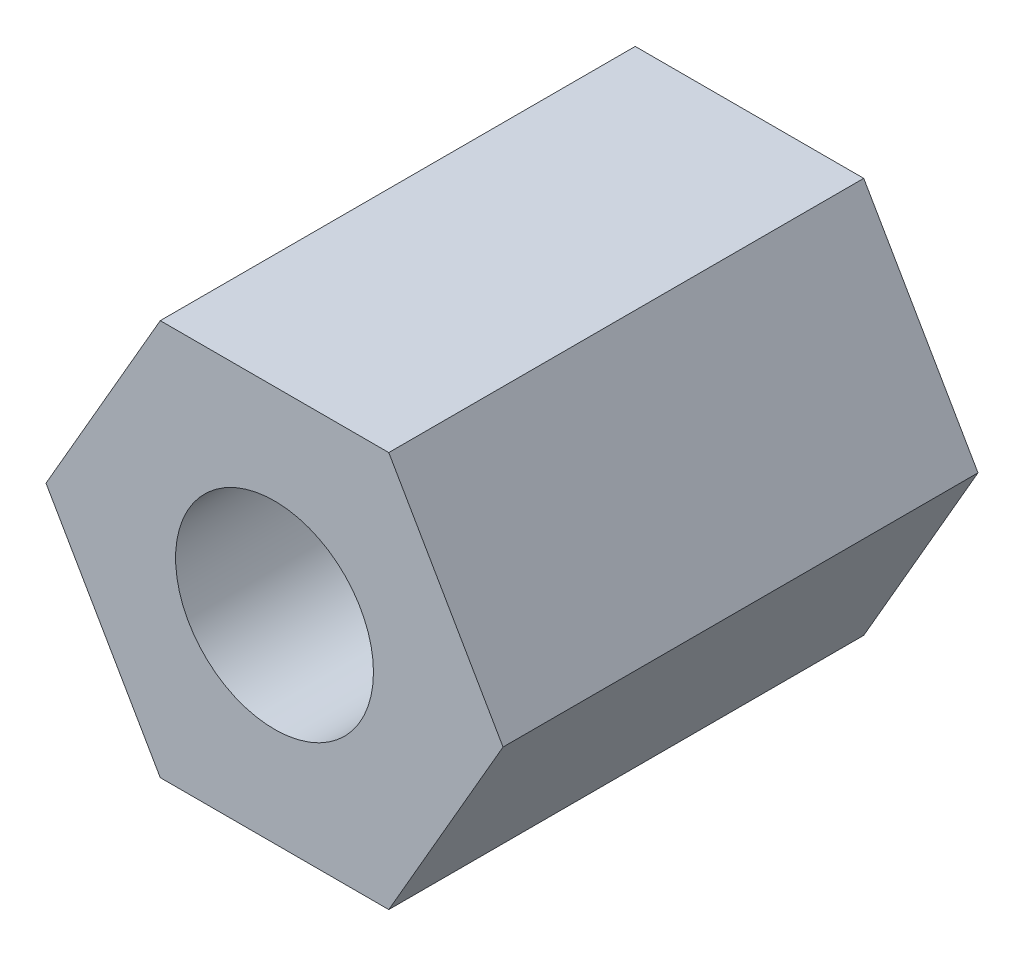
from build123d import *

# Parameters (mm, degrees)
ESTRUSIONE_ESTRUSIONE1_DEPTH = 3
SCHIZZO2_R                   = 1.25
TAGLIO_ESTRUSIONE1_DEPTH     = 7


with BuildPart() as part:
    # Schizzo1 → Estrusione-Estrusione1 (new body, symmetric)
    with BuildSketch(Plane.XY):
        Polygon((1.443375673, 2.5), (-1.443375673, 2.5), (-2.886751346, 0), (-1.443375673, -2.5), (1.443375673, -2.5), (2.886751346, 0), align=None)
    extrude(amount=ESTRUSIONE_ESTRUSIONE1_DEPTH, both=True)

    # Schizzo2 → Taglio-Estrusione1 (cut, through all)
    with BuildSketch(Plane.XY.offset(3)):
        Circle(SCHIZZO2_R)
    extrude(amount=-TAGLIO_ESTRUSIONE1_DEPTH, mode=Mode.SUBTRACT)


solid = part.part
